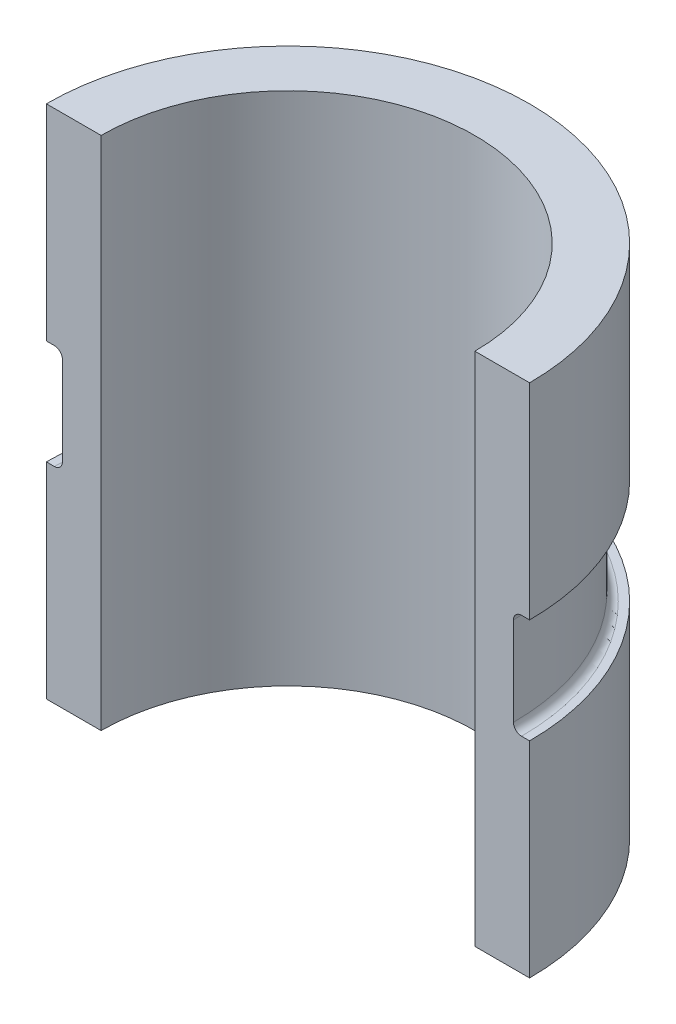
from build123d import *

# Parameters (mm, degrees)
BOSS_EXTRUDE1_DEPTH = 81.28
SKETCH2_W           = 2.54
SKETCH2_H           = 16.51
CUT_REVOLVE1_ANGLE  = 180
FILLET1_R           = 1.27


with BuildPart() as part:
    # Sketch1 → Boss-Extrude1 (new body)
    with BuildSketch(Plane(origin=(0, 0, 0), x_dir=(1, 0, 0), z_dir=(0, 1, 0))):
        with BuildLine():
            Line((-29.464, 0), (-38.1, 0))
            ThreePointArc((-38.1, 0), (0, 38.1), (38.1, 0))
            Line((38.1, 0), (29.464, 0))
            ThreePointArc((29.464, 0), (0, 29.464), (-29.464, 0))
        make_face()
    extrude(amount=BOSS_EXTRUDE1_DEPTH)

    # Sketch2 → Cut-Revolve1 (revolve, cut)
    with BuildSketch(Plane.XY):
        with Locations((-36.83, 40.64)):
            Rectangle(SKETCH2_W, SKETCH2_H)
    revolve(axis=Axis((0, 0, 0), (0, -1, 0)), revolution_arc=CUT_REVOLVE1_ANGLE, mode=Mode.SUBTRACT)

    # Fillet1
    fillet1_edges = [part.edges().sort_by_distance(p)[0] for p in [
        (0, 48.895, -35.56),
        (0, 32.385, -35.56),
    ]]
    fillet(fillet1_edges, radius=FILLET1_R)


solid = part.part
